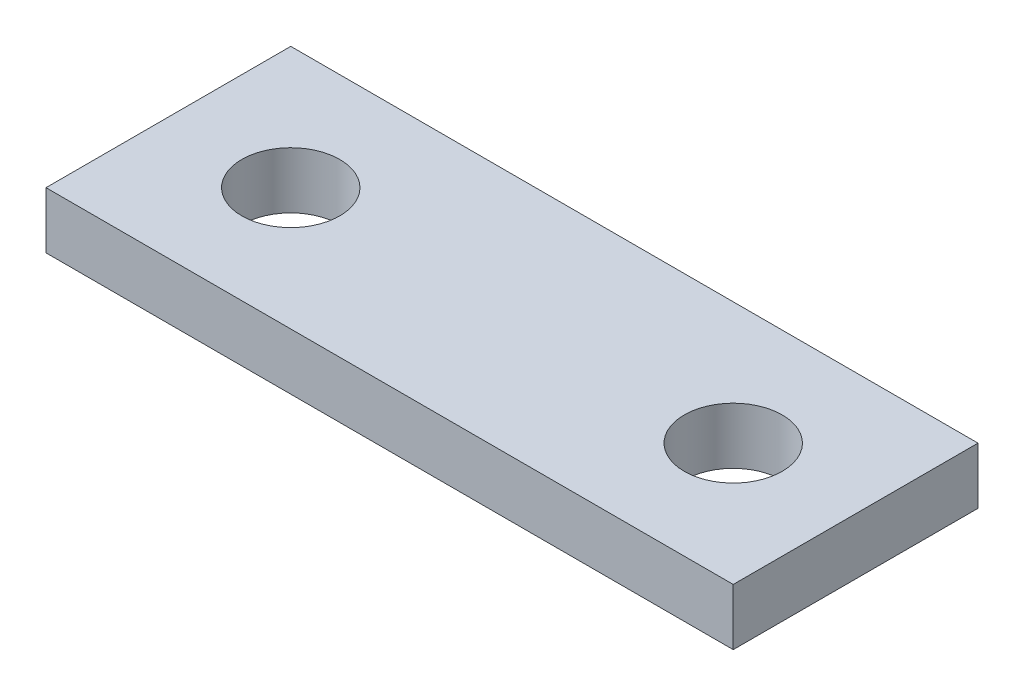
from build123d import *

# Parameters (mm, degrees)
ESQUISSE1_W        = 18.25
ESQUISSE1_H        = 13
ESQUISSE1_R        = 2.6
BOSS_EXTRU_1_DEPTH = 3


with BuildPart() as part:
    # Esquisse1 → Boss.-Extru.1 (new body)
    with BuildSketch(Plane(origin=(0, 0, 0), x_dir=(1, 0, 0), z_dir=(0, 1, 0))):
        with Locations((-9.125, 6.5)):
            Rectangle(ESQUISSE1_W, ESQUISSE1_H)
        with Locations((-11.75, 6.5)):
            Circle(ESQUISSE1_R, mode=Mode.SUBTRACT)
    boss_extru_1 = extrude(amount=BOSS_EXTRU_1_DEPTH)

    # Symétrie1: Boss.-Extru.1 across plane
    add(boss_extru_1.mirror(Plane(origin=(0, 0, 0), x_dir=(0, 0, 1), z_dir=(1, 0, 0))))


solid = part.part
